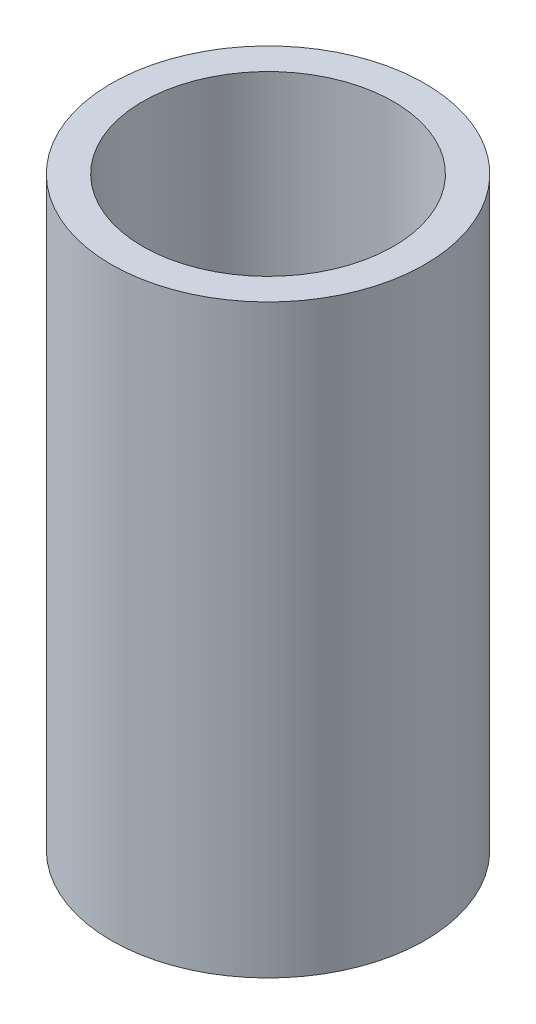
from build123d import *

# Parameters (mm, degrees)
SKETCH1_R           = 7.5
SKETCH1_R_2         = 6
BOSS_EXTRUDE1_DEPTH = 14


with BuildPart() as part:
    # Sketch1 → Boss-Extrude1 (new body, symmetric)
    with BuildSketch(Plane(origin=(0, 0, 0), x_dir=(1, 0, 0), z_dir=(0, 1, 0))):
        Circle(SKETCH1_R)
        Circle(SKETCH1_R_2, mode=Mode.SUBTRACT)
    extrude(amount=BOSS_EXTRUDE1_DEPTH, both=True)


solid = part.part
